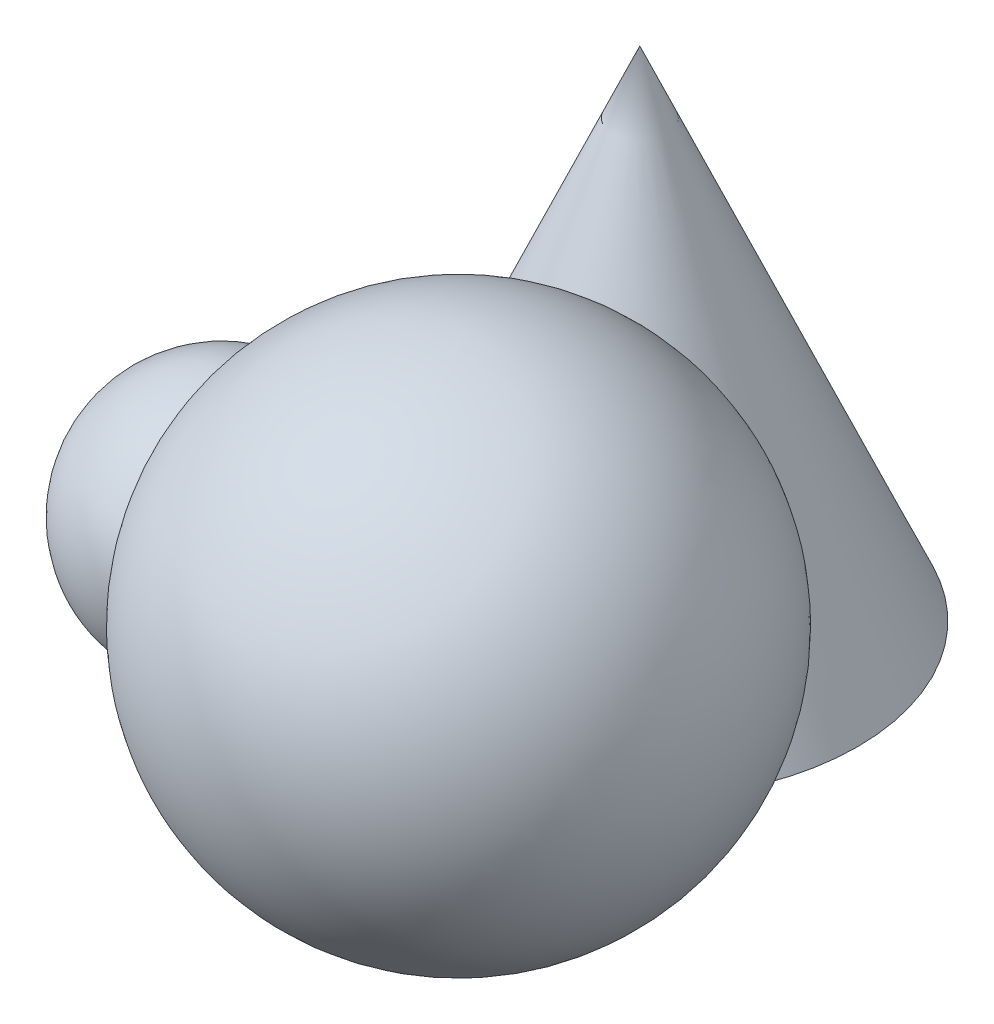
from build123d import *


with BuildPart() as part:
    # Sketch1 → Revolve1 (revolve)
    with BuildSketch(Plane.XY):
        Polygon((0, 0), (35, 0), (0, 80), align=None)
    revolve(axis=Axis((0, 80, 0), (0, -1, 0)))


with BuildPart() as body_2:
    # Sketch3 → Revolve2 (revolve)
    with BuildSketch(Plane(origin=(0, 40, 0), x_dir=(-1, 0, 0), z_dir=(0, 1, 0))):
        with BuildLine():
            Line((-26.160622991, 15.28330317), (-26.160622991, 95.28330317))
            ThreePointArc((-26.160622991, 95.28330317), (-66.160622991, 55.28330317), (-26.160622991, 15.28330317))
        make_face()
    revolve(axis=Axis((26.160622991, 40, 0), (0, 0, 1)))


with BuildPart() as body_3:
    # Sketch7 → Revolve3 (revolve)
    with BuildSketch(Plane(origin=(0, 20, 0), x_dir=(-1, 0, 0), z_dir=(0, 1, 0))):
        with BuildLine():
            Line((28.032483073, 59.062721952), (28.032483073, 19.062721952))
            ThreePointArc((28.032483073, 19.062721952), (48.032483073, 39.062721952), (28.032483073, 59.062721952))
        make_face()
    revolve(axis=Axis((-28.032483073, 20, 59.062721952), (0, 0, -1)))


solid = Compound([part.part, body_2.part, body_3.part])
